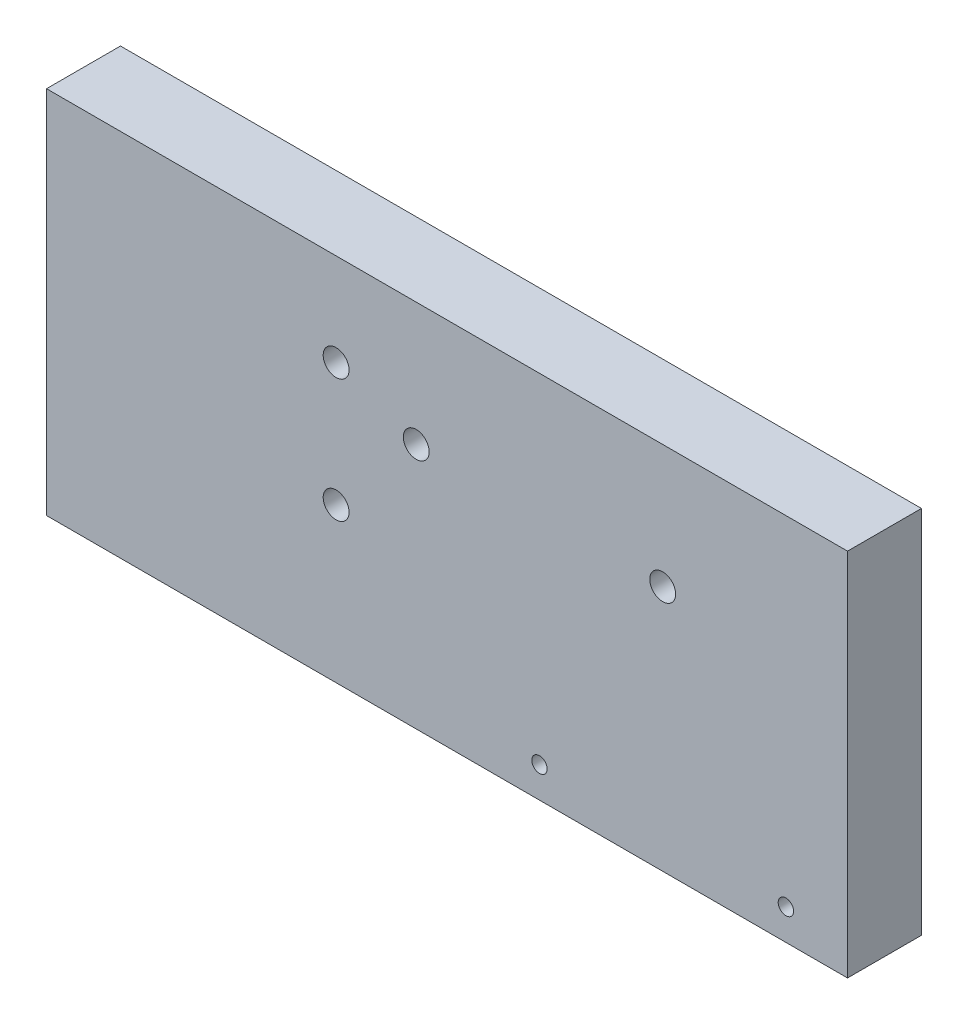
from build123d import *

# Parameters (mm, degrees)
SKETCH1_W             = 130
SKETCH1_H             = 60
BOSS_EXTRUDE1_DEPTH   = 6
M5X0_8_TAPPED_HOLE1_D = 4.2
M3X0_5_TAPPED_HOLE1_D = 2.5


with BuildPart() as part:
    # Sketch1 → Boss-Extrude1 (new body, symmetric)
    with BuildSketch(Plane.XY):
        Rectangle(SKETCH1_W, SKETCH1_H)
    extrude(amount=BOSS_EXTRUDE1_DEPTH, both=True)

    # M5x0.8 Tapped Hole1 (through all)
    with Locations(Plane.XY.offset(6)):
        with Locations((-18, 15), (-18, -5), (-5, 10), (35, 10)):
            Hole(M5X0_8_TAPPED_HOLE1_D / 2)

    # M3x0.5 Tapped Hole1 (through all)
    with Locations(Plane.XY.offset(6)):
        with Locations((15, -25), (55, -25)):
            Hole(M3X0_5_TAPPED_HOLE1_D / 2)


solid = part.part
